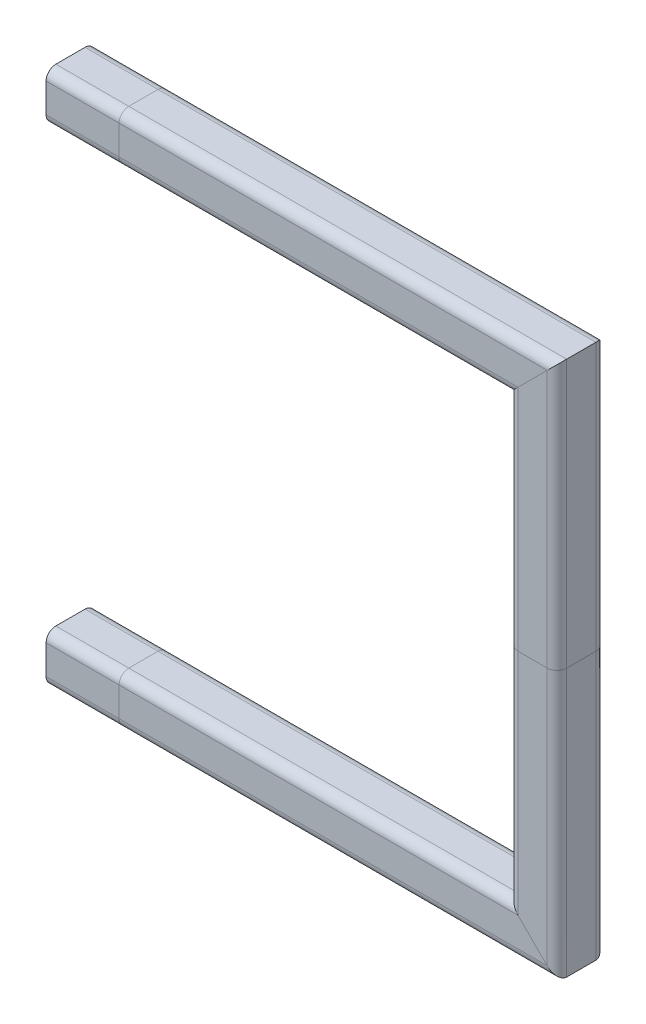
from build123d import *

# Parameters (mm, degrees)
SQUARE_TUBE_20_X_20_X_2_1_DEPTH      = 1
SQUARE_TUBE_20_X_20_X_2_1_DEPTH_BACK = 30
SQUARE_TUBE_20_X_20_X_2_1_2_DEPTH    = 186.142135624
SQUARE_TUBE_20_X_20_X_2_1_3_DEPTH    = 116.142135624
SQUARE_TUBE_20_X_20_X_2_1_4_DEPTH    = 116.142135624
SQUARE_TUBE_20_X_20_X_2_1_5_DEPTH    = 186.142135624
SQUARE_TUBE_20_X_20_X_2_1_6_DEPTH    = 31


with BuildPart() as part:
    # Sketch11 → Square tube 20 X 20 X 2(1) (new, two sides)
    with BuildSketch(Plane.YZ) as square_tube_20_x_20_x_2_1_sk:
        with BuildLine():
            Line((-6, -10), (6, -10))
            ThreePointArc((6, -10), (8.828427125, -8.828427125), (10, -6))
            Line((10, -6), (10, 6))
            ThreePointArc((10, 6), (8.828427125, 8.828427125), (6, 10))
            Line((6, 10), (-6, 10))
            ThreePointArc((-6, 10), (-8.828427125, 8.828427125), (-10, 6))
            Line((-10, 6), (-10, -6))
            ThreePointArc((-10, -6), (-8.828427125, -8.828427125), (-6, -10))
        make_face()
        with BuildLine():
            Line((-6, -8), (6, -8))
            ThreePointArc((6, -8), (7.414213562, -7.414213562), (8, -6))
            Line((8, -6), (8, 6))
            ThreePointArc((8, 6), (7.414213562, 7.414213562), (6, 8))
            Line((6, 8), (-6, 8))
            ThreePointArc((-6, 8), (-7.414213562, 7.414213562), (-8, 6))
            Line((-8, 6), (-8, -6))
            ThreePointArc((-8, -6), (-7.414213562, -7.414213562), (-6, -8))
        make_face(mode=Mode.SUBTRACT)
    extrude(amount=SQUARE_TUBE_20_X_20_X_2_1_DEPTH)
    extrude(square_tube_20_x_20_x_2_1_sk.sketch, amount=-SQUARE_TUBE_20_X_20_X_2_1_DEPTH_BACK)

    # Square tube 20 X 20 X 2(1) mitre 1
    split(bisect_by=Plane(origin=(0, 0, 0), x_dir=(0, -1, 0), z_dir=(-1, 0, 0)), keep=Keep.TOP)


with BuildPart() as body_2:
    # Sketch11 on segment 2 (carried to segment 2) → Square tube 20 X 20 X 2_1 2 (new body)
    with BuildSketch(Plane.YZ.offset(-1)):
        with BuildLine():
            Line((-6, -10), (6, -10))
            ThreePointArc((6, -10), (8.828427125, -8.828427125), (10, -6))
            Line((10, -6), (10, 6))
            ThreePointArc((10, 6), (8.828427125, 8.828427125), (6, 10))
            Line((6, 10), (-6, 10))
            ThreePointArc((-6, 10), (-8.828427125, 8.828427125), (-10, 6))
            Line((-10, 6), (-10, -6))
            ThreePointArc((-10, -6), (-8.828427125, -8.828427125), (-6, -10))
        make_face()
        with BuildLine():
            Line((-6, -8), (6, -8))
            ThreePointArc((6, -8), (7.414213562, -7.414213562), (8, -6))
            Line((8, -6), (8, 6))
            ThreePointArc((8, 6), (7.414213562, 7.414213562), (6, 8))
            Line((6, 8), (-6, 8))
            ThreePointArc((-6, 8), (-7.414213562, 7.414213562), (-8, 6))
            Line((-8, 6), (-8, -6))
            ThreePointArc((-8, -6), (-7.414213562, -7.414213562), (-6, -8))
        make_face(mode=Mode.SUBTRACT)
    extrude(amount=SQUARE_TUBE_20_X_20_X_2_1_2_DEPTH)

    # Square tube 20 X 20 X 2_1 2 mitre 1
    split(bisect_by=Plane.YZ, keep=Keep.TOP)

    # Square tube 20 X 20 X 2_1 2 mitre 2
    split(bisect_by=Plane(origin=(170, 0, 0), x_dir=(0.707106781, -0.707106781, 0), z_dir=(-0.707106781, -0.707106781, 0)), keep=Keep.TOP)


with BuildPart() as body_3:
    # Sketch11 on segment 3 (carried to segment 3) → Square tube 20 X 20 X 2_1 3 (new body)
    with BuildSketch(Plane(origin=(170, -15.142135624, 0), x_dir=(-1, 0, 0), z_dir=(0, 1, 0))):
        with BuildLine():
            Line((-6, -10), (6, -10))
            ThreePointArc((6, -10), (8.828427125, -8.828427125), (10, -6))
            Line((10, -6), (10, 6))
            ThreePointArc((10, 6), (8.828427125, 8.828427125), (6, 10))
            Line((6, 10), (-6, 10))
            ThreePointArc((-6, 10), (-8.828427125, 8.828427125), (-10, 6))
            Line((-10, 6), (-10, -6))
            ThreePointArc((-10, -6), (-8.828427125, -8.828427125), (-6, -10))
        make_face()
        with BuildLine():
            Line((-6, -8), (6, -8))
            ThreePointArc((6, -8), (7.414213562, -7.414213562), (8, -6))
            Line((8, -6), (8, 6))
            ThreePointArc((8, 6), (7.414213562, 7.414213562), (6, 8))
            Line((6, 8), (-6, 8))
            ThreePointArc((-6, 8), (-7.414213562, 7.414213562), (-8, 6))
            Line((-8, 6), (-8, -6))
            ThreePointArc((-8, -6), (-7.414213562, -7.414213562), (-6, -8))
        make_face(mode=Mode.SUBTRACT)
    extrude(amount=SQUARE_TUBE_20_X_20_X_2_1_3_DEPTH)

    # Square tube 20 X 20 X 2_1 3 mitre 1
    split(bisect_by=Plane(origin=(170, 100, 0), x_dir=(1, 0, 0), z_dir=(0, -1, 0)), keep=Keep.TOP)

    # Square tube 20 X 20 X 2_1 3 mitre 2
    split(bisect_by=Plane(origin=(170, 0, 0), x_dir=(-0.707106781, 0.707106781, 0), z_dir=(0.707106781, 0.707106781, 0)), keep=Keep.TOP)


with BuildPart() as body_4:
    # Sketch11 on segment 4 (carried to segment 4) → Square tube 20 X 20 X 2_1 4 (new body)
    with BuildSketch(Plane(origin=(170, 99, 0), x_dir=(-1, 0, 0), z_dir=(0, 1, 0))):
        with BuildLine():
            Line((-6, -10), (6, -10))
            ThreePointArc((6, -10), (8.828427125, -8.828427125), (10, -6))
            Line((10, -6), (10, 6))
            ThreePointArc((10, 6), (8.828427125, 8.828427125), (6, 10))
            Line((6, 10), (-6, 10))
            ThreePointArc((-6, 10), (-8.828427125, 8.828427125), (-10, 6))
            Line((-10, 6), (-10, -6))
            ThreePointArc((-10, -6), (-8.828427125, -8.828427125), (-6, -10))
        make_face()
        with BuildLine():
            Line((-6, -8), (6, -8))
            ThreePointArc((6, -8), (7.414213562, -7.414213562), (8, -6))
            Line((8, -6), (8, 6))
            ThreePointArc((8, 6), (7.414213562, 7.414213562), (6, 8))
            Line((6, 8), (-6, 8))
            ThreePointArc((-6, 8), (-7.414213562, 7.414213562), (-8, 6))
            Line((-8, 6), (-8, -6))
            ThreePointArc((-8, -6), (-7.414213562, -7.414213562), (-6, -8))
        make_face(mode=Mode.SUBTRACT)
    extrude(amount=SQUARE_TUBE_20_X_20_X_2_1_4_DEPTH)

    # Square tube 20 X 20 X 2_1 4 mitre 1
    split(bisect_by=Plane(origin=(170, 200, 0), x_dir=(0.707106781, 0.707106781, 0), z_dir=(0.707106781, -0.707106781, 0)), keep=Keep.TOP)

    # Square tube 20 X 20 X 2_1 4 mitre 2
    split(bisect_by=Plane(origin=(170, 100, 0), x_dir=(-1, 0, 0), z_dir=(0, 1, 0)), keep=Keep.TOP)


with BuildPart() as body_5:
    # Sketch11 on segment 5 (carried to segment 5) → Square tube 20 X 20 X 2_1 5 (new body)
    with BuildSketch(Plane(origin=(185.142135624, 200, 0), x_dir=(0, -1, 0), z_dir=(-1, 0, 0))):
        with BuildLine():
            Line((-6, -10), (6, -10))
            ThreePointArc((6, -10), (8.828427125, -8.828427125), (10, -6))
            Line((10, -6), (10, 6))
            ThreePointArc((10, 6), (8.828427125, 8.828427125), (6, 10))
            Line((6, 10), (-6, 10))
            ThreePointArc((-6, 10), (-8.828427125, 8.828427125), (-10, 6))
            Line((-10, 6), (-10, -6))
            ThreePointArc((-10, -6), (-8.828427125, -8.828427125), (-6, -10))
        make_face()
        with BuildLine():
            Line((-6, -8), (6, -8))
            ThreePointArc((6, -8), (7.414213562, -7.414213562), (8, -6))
            Line((8, -6), (8, 6))
            ThreePointArc((8, 6), (7.414213562, 7.414213562), (6, 8))
            Line((6, 8), (-6, 8))
            ThreePointArc((-6, 8), (-7.414213562, 7.414213562), (-8, 6))
            Line((-8, 6), (-8, -6))
            ThreePointArc((-8, -6), (-7.414213562, -7.414213562), (-6, -8))
        make_face(mode=Mode.SUBTRACT)
    extrude(amount=SQUARE_TUBE_20_X_20_X_2_1_5_DEPTH)

    # Square tube 20 X 20 X 2_1 5 mitre 1
    split(bisect_by=Plane(origin=(0, 200, 0), x_dir=(0, 1, 0), z_dir=(1, 0, 0)), keep=Keep.TOP)

    # Square tube 20 X 20 X 2_1 5 mitre 2
    split(bisect_by=Plane(origin=(170, 200, 0), x_dir=(-0.707106781, -0.707106781, 0), z_dir=(-0.707106781, 0.707106781, 0)), keep=Keep.TOP)


with BuildPart() as body_6:
    # Sketch11 on segment 6 (carried to segment 6) → Square tube 20 X 20 X 2_1 6 (new body)
    with BuildSketch(Plane(origin=(1, 200, 0), x_dir=(0, -1, 0), z_dir=(-1, 0, 0))):
        with BuildLine():
            Line((-6, -10), (6, -10))
            ThreePointArc((6, -10), (8.828427125, -8.828427125), (10, -6))
            Line((10, -6), (10, 6))
            ThreePointArc((10, 6), (8.828427125, 8.828427125), (6, 10))
            Line((6, 10), (-6, 10))
            ThreePointArc((-6, 10), (-8.828427125, 8.828427125), (-10, 6))
            Line((-10, 6), (-10, -6))
            ThreePointArc((-10, -6), (-8.828427125, -8.828427125), (-6, -10))
        make_face()
        with BuildLine():
            Line((-6, -8), (6, -8))
            ThreePointArc((6, -8), (7.414213562, -7.414213562), (8, -6))
            Line((8, -6), (8, 6))
            ThreePointArc((8, 6), (7.414213562, 7.414213562), (6, 8))
            Line((6, 8), (-6, 8))
            ThreePointArc((-6, 8), (-7.414213562, 7.414213562), (-8, 6))
            Line((-8, 6), (-8, -6))
            ThreePointArc((-8, -6), (-7.414213562, -7.414213562), (-6, -8))
        make_face(mode=Mode.SUBTRACT)
    extrude(amount=SQUARE_TUBE_20_X_20_X_2_1_6_DEPTH)

    # Square tube 20 X 20 X 2_1 6 mitre 1
    split(bisect_by=Plane(origin=(0, 200, 0), x_dir=(0, -1, 0), z_dir=(-1, 0, 0)), keep=Keep.TOP)


solid = Compound([part.part, body_2.part, body_3.part, body_4.part, body_5.part, body_6.part])
